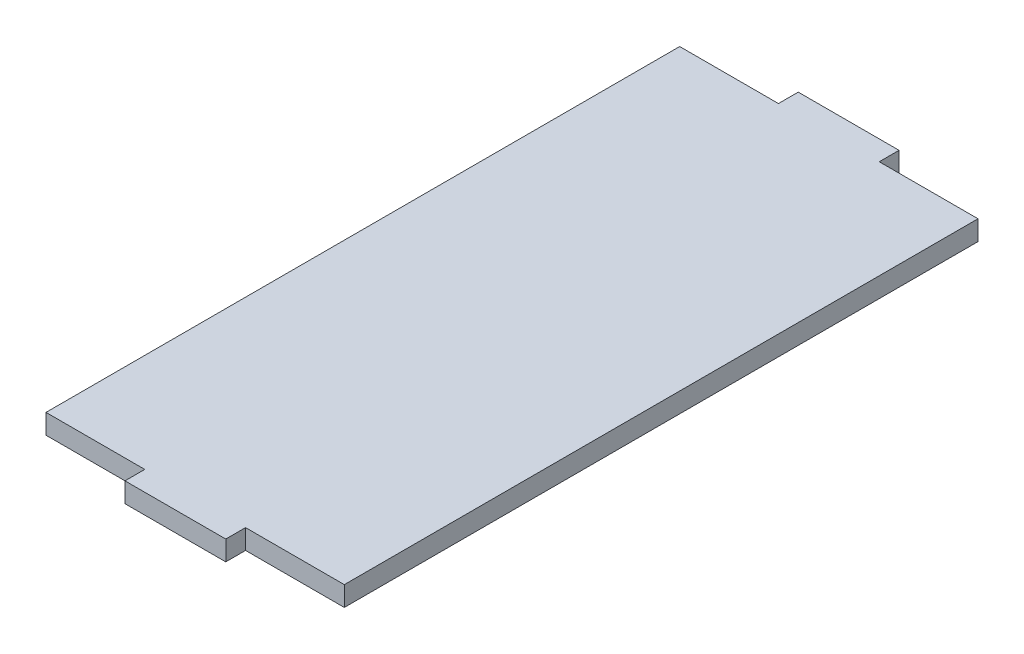
from build123d import *

# Parameters (mm, degrees)
SKETCH1_W           = 47.83
SKETCH1_H           = 101.6
BOSS_EXTRUDE1_DEPTH = 3.175
SKETCH2_W           = 16.16
SKETCH2_H           = 3.175
BOSS_EXTRUDE2_DEPTH = 3.175


with BuildPart() as part:
    # Sketch1 → Boss-Extrude1 (new body)
    with BuildSketch(Plane(origin=(0, 0, 0), x_dir=(1, 0, 0), z_dir=(0, 1, 0))):
        with Locations((6.023807387, 19.092830869)):
            Rectangle(SKETCH1_W, SKETCH1_H)
    extrude(amount=BOSS_EXTRUDE1_DEPTH)

    # Sketch2 → Boss-Extrude2 (add)
    with BuildSketch(Plane(origin=(0, 3.175, 0), x_dir=(1, 0, 0), z_dir=(0, 1, 0))):
        with Locations((6.023807387, 71.480330869)):
            Rectangle(SKETCH2_W, SKETCH2_H)
        with Locations((6.023807387, -33.294669131)):
            Rectangle(SKETCH2_W, SKETCH2_H)
    extrude(amount=-BOSS_EXTRUDE2_DEPTH)


solid = part.part
